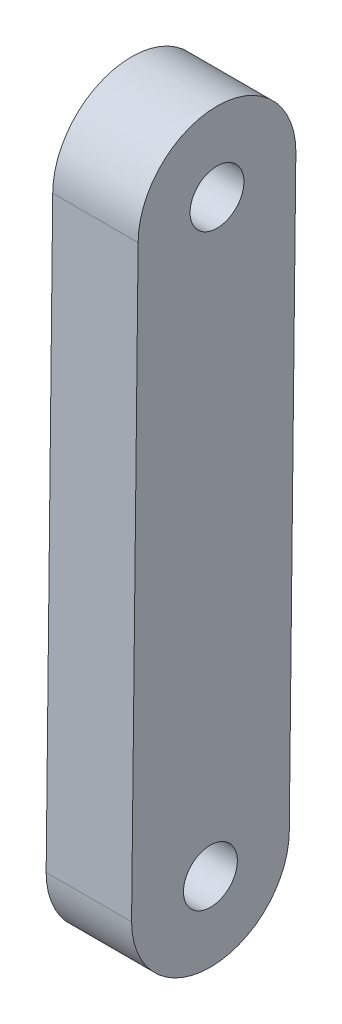
from build123d import *

# Parameters (mm, degrees)
SKETCH1_R           = 2.05
BOSS_EXTRUDE1_DEPTH = 6.5


with BuildPart() as part:
    # Sketch1 → Boss-Extrude1 (new body)
    with BuildSketch(Plane(origin=(-14.5, 0, 0), x_dir=(0, 0, -1), z_dir=(1, 0, 0))):
        with BuildLine():
            ThreePointArc((-17.5, -136.5), (-23.5, -130.5), (-29.5, -136.5))
            Line((-29.5, -136.5), (-30, -181))
            ThreePointArc((-30, -181), (-27.287286528, -186.019337335), (-21.602084238, -186.5))
            Line((-21.602084238, -186.5), (-24, -186.5))
            ThreePointArc((-24, -186.5), (-29.5, -181), (-24, -175.5))
            Line((-24, -175.5), (-17.938202247, -175.5))
            Line((-17.938202247, -175.5), (-17.5, -136.5))
        make_face()
        with Locations((-23.5, -136.5)):
            Circle(SKETCH1_R, mode=Mode.SUBTRACT)
        with BuildLine():
            Line((-24, -186.5), (-21.602084238, -186.5))
            ThreePointArc((-21.602084238, -186.5), (-18.980662665, -184.287286528), (-18, -181))
            Line((-18, -181), (-17.938202247, -175.5))
            Line((-17.938202247, -175.5), (-24, -175.5))
            ThreePointArc((-24, -175.5), (-29.5, -181), (-24, -186.5))
        make_face()
        with Locations((-24, -181)):
            Circle(SKETCH1_R, mode=Mode.SUBTRACT)
    extrude(amount=BOSS_EXTRUDE1_DEPTH)


solid = part.part
